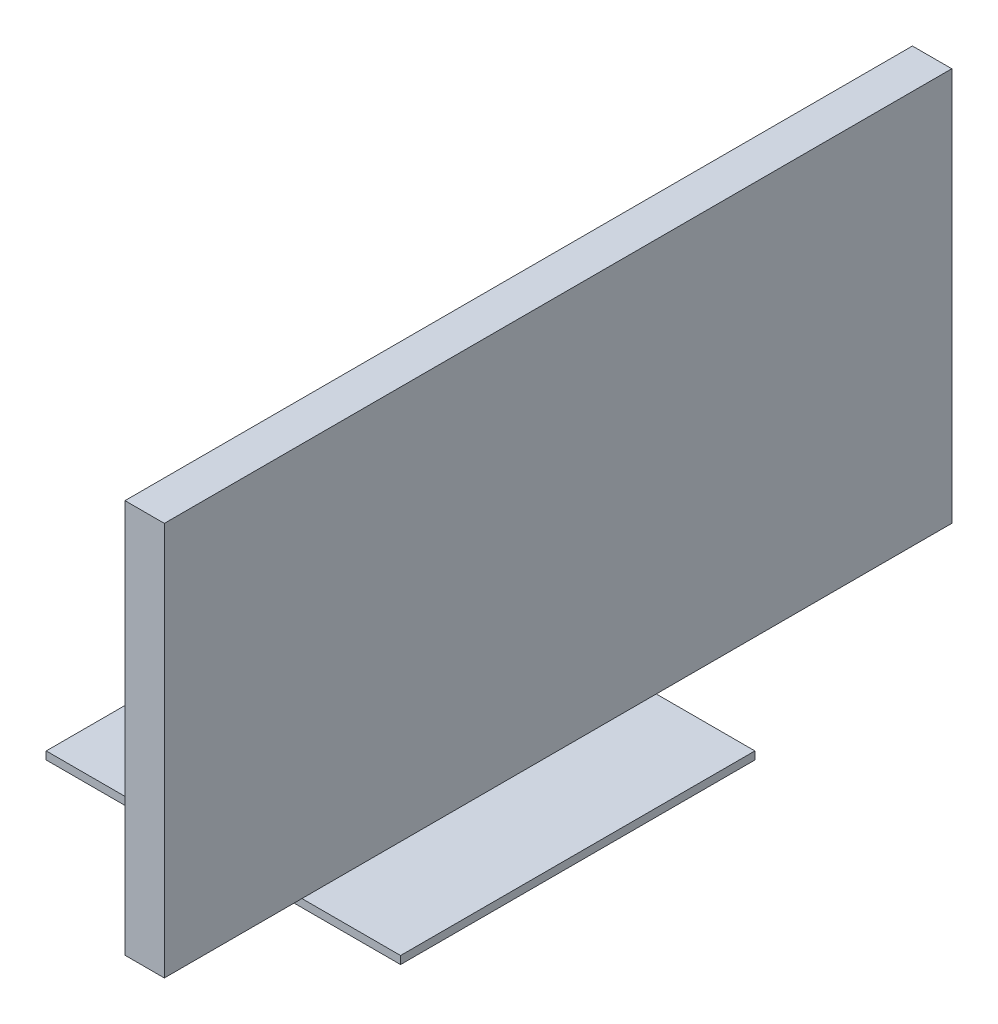
from build123d import *

# Parameters (mm, degrees)
SKETCH2_W           = 45
SKETCH2_H           = 45
BOSS_EXTRUDE1_DEPTH = 1
SKETCH4_W           = 10
SKETCH4_H           = 10
BOSS_EXTRUDE3_DEPTH = 40
CUT_EXTRUDE4_DEPTH  = 30
BOSS_EXTRUDE8_DEPTH = 10
SKETCH18_W          = 100
SKETCH18_H          = 50
BOSS_EXTRUDE9_DEPTH = 5


with BuildPart() as part:
    # Sketch2 → Boss-Extrude1 (new body)
    with BuildSketch(Plane(origin=(0, 0, 0), x_dir=(1, 0, 0), z_dir=(0, 1, 0))):
        with Locations((22.5, 22.5)):
            Rectangle(SKETCH2_W, SKETCH2_H)
    extrude(amount=BOSS_EXTRUDE1_DEPTH)

    # Sketch4 → Boss-Extrude3 (add)
    with BuildSketch(Plane(origin=(0, 1, 0), x_dir=(1, 0, 0), z_dir=(0, 1, 0))):
        with Locations((22.5, 22.5)):
            Rectangle(SKETCH4_W, SKETCH4_H)
    extrude(amount=BOSS_EXTRUDE3_DEPTH)

    # Sketch10 → Cut-Extrude4 (cut)
    with BuildSketch(Plane(origin=(17.5, 41, -17.5), x_dir=(1, 0, 0), z_dir=(0, 0, 1))):
        Polygon((0, 0), (10, -9.949648776), (17.910752022, -1.998863577), (8.35816631, 7.505623697), align=None)
    extrude(amount=-CUT_EXTRUDE4_DEPTH, mode=Mode.SUBTRACT)

    # Sketch16 → Boss-Extrude8 (add)
    with BuildSketch(Plane(origin=(17.5, 41, -17.5), x_dir=(1, 0, 0), z_dir=(0, 0, 1))):
        Polygon((10, -9.949648776), (0, 0), (20, 0), (20, -9.949648776), align=None)
    extrude(amount=-BOSS_EXTRUDE8_DEPTH)

    # Sketch18 → Boss-Extrude9 (add)
    with BuildSketch(Plane(origin=(37.5, 0, 0), x_dir=(0, 0, -1), z_dir=(1, 0, 0))):
        with Locations((22.5, 36.025175612)):
            Rectangle(SKETCH18_W, SKETCH18_H)
    extrude(amount=BOSS_EXTRUDE9_DEPTH)


solid = part.part
